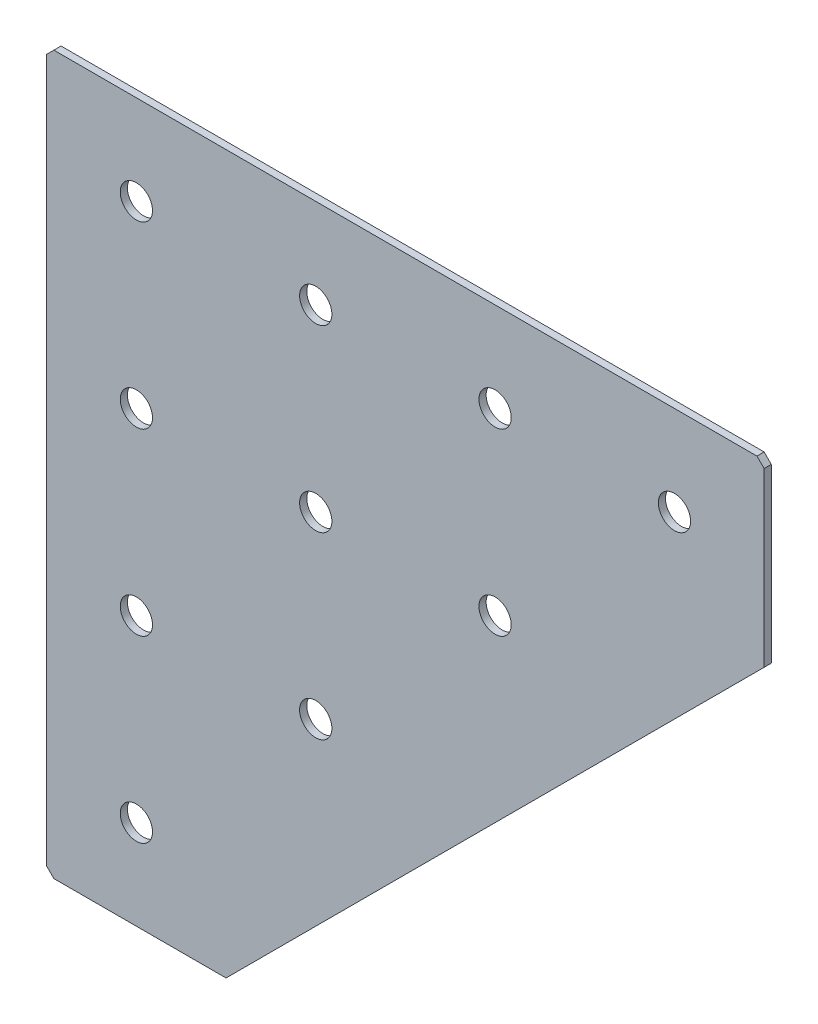
from build123d import *

# Parameters (mm, degrees)
EXTRUDE_1_DEPTH   = 2
CHAMFER_1_SIZE    = 2
HOLE_WIZARD_M81_D = 9


with BuildPart() as part:
    # Эскиз1 → Бобышка-Вытянуть1 (new body)
    with BuildSketch(Plane.XY):
        Polygon((0, 0), (0, -200), (50, -200), (200, -50), (200, 0), align=None)
    extrude(amount=EXTRUDE_1_DEPTH)

    # Фаска1
    chamfer_1_edges = [part.edges().sort_by_distance(p)[0] for p in [
        (200, 0, 1),
        (0, -200, 1),
        (0, 0, 1),
    ]]
    chamfer(chamfer_1_edges, length=CHAMFER_1_SIZE)

    # Отверстие с зазором M81 (through all)
    with Locations(Plane.XY.offset(2)):
        with Locations((25, -25), (75, -25), (125, -25), (175, -25), (25, -75), (25, -125), (25, -175), (75, -125), (125, -75), (75, -75)):
            Hole(HOLE_WIZARD_M81_D / 2)


solid = part.part
